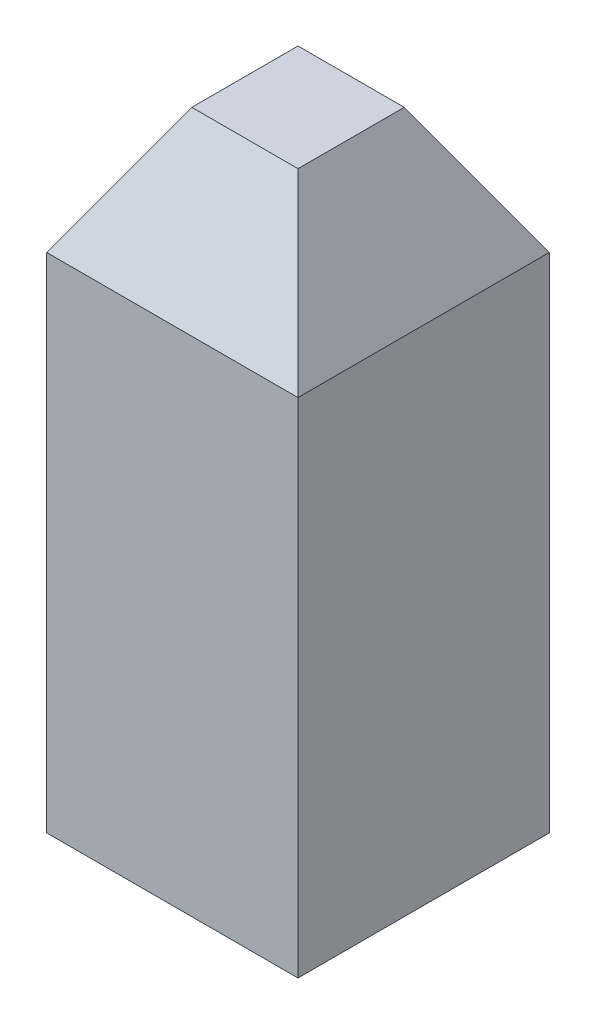
from build123d import *

# Parameters (mm, degrees)
SKETCH1_W           = 0.5
SKETCH1_H           = 0.5
BOSS_EXTRUDE1_DEPTH = 0.5
SKETCH2_W           = 0.5
SKETCH2_H           = 0.5
BOSS_EXTRUDE2_DEPTH = 0.25
BOSS_EXTRUDE2_TAPER = 30


with BuildPart() as part:
    # Sketch1 → Boss-Extrude1 (new body, symmetric)
    with BuildSketch(Plane(origin=(0, 0, 0), x_dir=(1, 0, 0), z_dir=(0, 1, 0))):
        Rectangle(SKETCH1_W, SKETCH1_H)
    extrude(amount=BOSS_EXTRUDE1_DEPTH, both=True)

    # Sketch2 → Boss-Extrude2 (add)
    with BuildSketch(Plane(origin=(0, 0.5, 0), x_dir=(1, 0, 0), z_dir=(0, 1, 0))):
        Rectangle(SKETCH2_W, SKETCH2_H)
    extrude(amount=BOSS_EXTRUDE2_DEPTH, taper=BOSS_EXTRUDE2_TAPER)


solid = part.part
